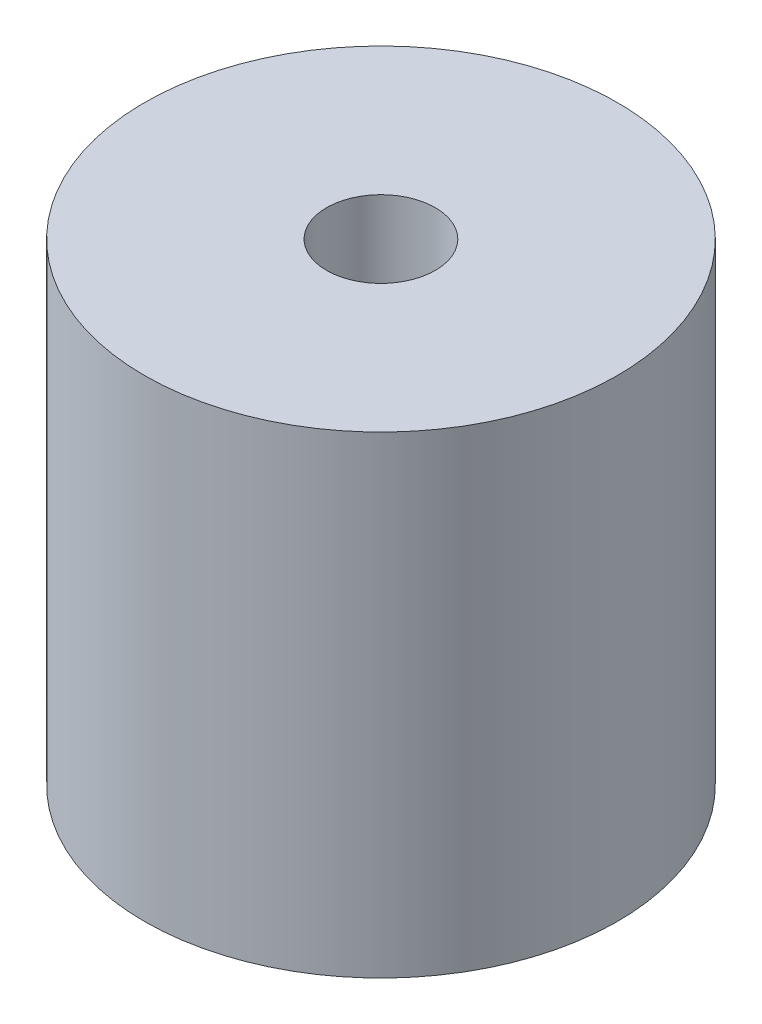
from build123d import *

# Parameters (mm, degrees)
SKETCH_1_R              = 5
EXTRUDE_1_DEPTH         = 10
SKETCH_2_R              = 4.501699131
SKETCH_2_R_2            = 2
CUT_EXTRUDE_1_DEPTH     = 0.5
HOLE_WIZARD_M2_21_D     = 2.3
HOLE_WIZARD_M2_21_DEPTH = 2
HOLE_WIZARD_M2_21_TIP   = 0.690989712


with BuildPart() as part:
    # Эскиз1 → Бобышка-Вытянуть1 (new body)
    with BuildSketch(Plane(origin=(0, 0, 0), x_dir=(1, 0, 0), z_dir=(0, 1, 0))):
        Circle(SKETCH_1_R)
    extrude(amount=EXTRUDE_1_DEPTH)

    # Эскиз2 → Вырез-Вытянуть1 (cut)
    with BuildSketch(Plane.XZ):
        Circle(SKETCH_2_R)
        Circle(SKETCH_2_R_2, mode=Mode.SUBTRACT)
    extrude(amount=-CUT_EXTRUDE_1_DEPTH, mode=Mode.SUBTRACT)

    # Сверло под метчик  спиральное M2.21
    with Locations(Plane(origin=(0, 10, 0), x_dir=(1, 0, 0), z_dir=(0, 1, 0))):
        with Locations((0, 0)):
            Hole(HOLE_WIZARD_M2_21_D / 2, depth=HOLE_WIZARD_M2_21_DEPTH)
            with Locations((0, 0, -(HOLE_WIZARD_M2_21_DEPTH + HOLE_WIZARD_M2_21_TIP / 2))):  # 118° drill point
                Cone(0, HOLE_WIZARD_M2_21_D / 2, HOLE_WIZARD_M2_21_TIP, mode=Mode.SUBTRACT)


solid = part.part
